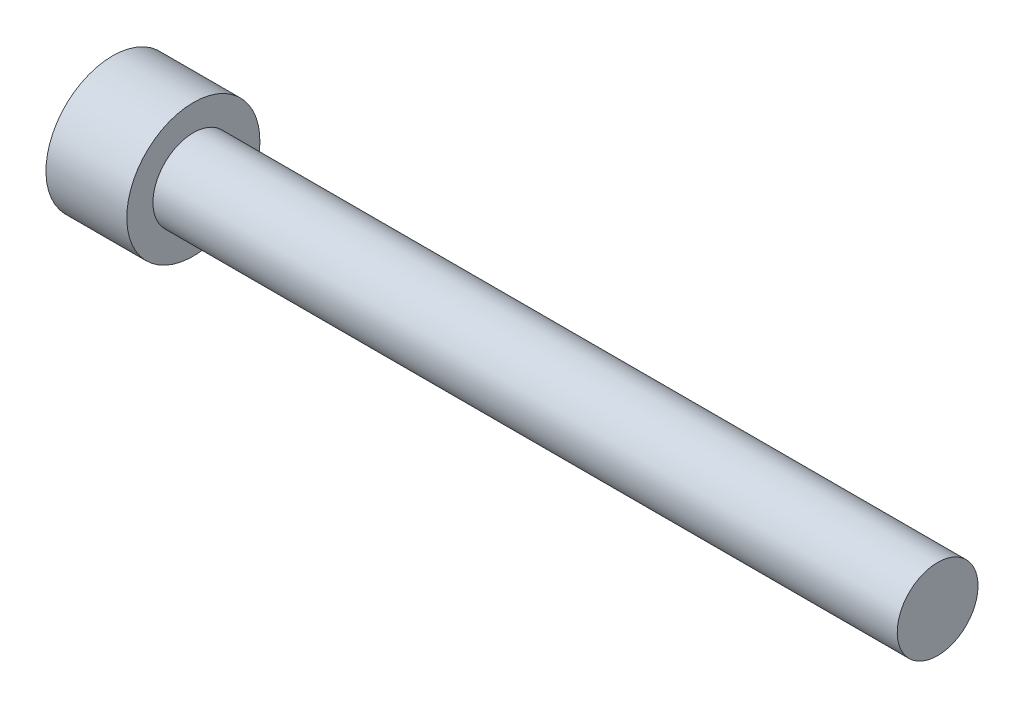
from build123d import *


with BuildPart() as part:
    # Sketch1 → Revolve1 (revolve)
    with BuildSketch(Plane.XY):
        Polygon((0, 2.413), (44.45, 2.413), (44.45, 0), (-4.826, 0), (-4.826, 3.9751), (0, 3.9751), align=None)
    revolve(axis=Axis((44.45, 0, 0), (-1, 0, 0)))


solid = part.part
